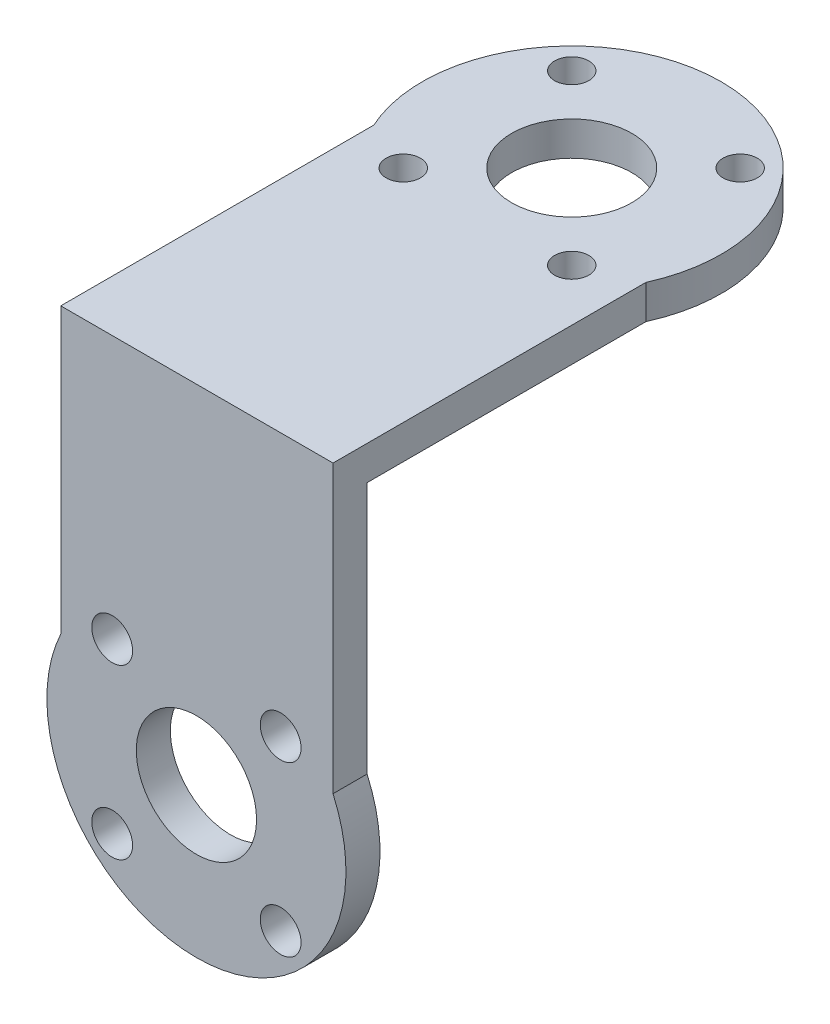
from build123d import *

# Parameters (mm, degrees)
CROQUIS1_R              = 5.3
CROQUIS1_R_2            = 1.511434147
SALIENTE_EXTRUIR1_DEPTH = 3
CROQUIS3_R              = 1.8
CROQUIS3_R_2            = 5.3
SALIENTE_EXTRUIR2_DEPTH = 3


with BuildPart() as part:
    # Croquis1 → Saliente-Extruir1 (new body)
    with BuildSketch(Plane(origin=(0, 0, 0), x_dir=(1, 0, 0), z_dir=(0, 1, 0))):
        with BuildLine():
            Line((10.649291245, -23.45570863), (10.649291245, 1.133383189))
            ThreePointArc((10.649291245, 1.133383189), (-1.350708755, 19.76429137), (-13.350708755, 1.133383189))
            Line((-13.350708755, 1.133383189), (-13.350708755, -23.45570863))
            Line((-13.350708755, -23.45570863), (10.649291245, -23.45570863))
        make_face()
        with Locations((-1.350708755, 6.58429137)):
            Circle(CROQUIS1_R, mode=Mode.SUBTRACT)
        with Locations((6.073912448, 14.008912573)):
            Circle(CROQUIS1_R_2, mode=Mode.SUBTRACT)
        with Locations((6.073912448, -0.840329832)):
            Circle(CROQUIS1_R_2, mode=Mode.SUBTRACT)
        with Locations((-8.775329957, -0.840329832)):
            Circle(CROQUIS1_R_2, mode=Mode.SUBTRACT)
        with Locations((-8.775329957, 14.008912573)):
            Circle(CROQUIS1_R_2, mode=Mode.SUBTRACT)
    extrude(amount=SALIENTE_EXTRUIR1_DEPTH)

    # Croquis3 → Saliente-Extruir2 (add)
    with BuildSketch(Plane.XY.offset(23.45570863)):
        with BuildLine():
            Line((10.649291245, 3), (-13.350708755, 3))
            Line((-13.350708755, 3), (-13.350708755, -22.057235679))
            ThreePointArc((-13.350708755, -22.057235679), (-1.494791792, -40.779605827), (10.649291245, -22.242854272))
            Line((10.649291245, -22.242854272), (10.649291245, 3))
        make_face()
        with Locations((-8.817480498, -35.024621202)):
            Circle(CROQUIS3_R, mode=Mode.SUBTRACT)
        with Locations((-8.817480498, -20.175378798)):
            Circle(CROQUIS3_R, mode=Mode.SUBTRACT)
        with Locations((6.031761906, -20.175378798)):
            Circle(CROQUIS3_R, mode=Mode.SUBTRACT)
        with Locations((6.031761906, -35.024621202)):
            Circle(CROQUIS3_R, mode=Mode.SUBTRACT)
        with Locations((-1.392859296, -27.6)):
            Circle(CROQUIS3_R_2, mode=Mode.SUBTRACT)
    extrude(amount=SALIENTE_EXTRUIR2_DEPTH)


solid = part.part
